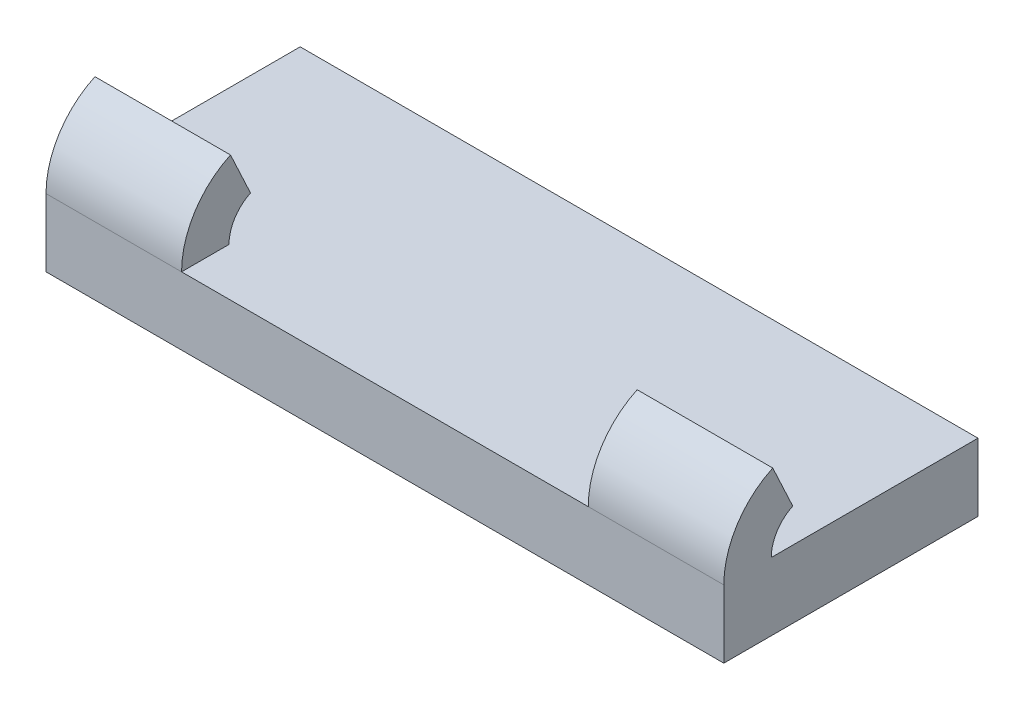
from build123d import *

# Parameters (mm, degrees)
SKETCH1_W           = 50.8
SKETCH1_H           = 19.05
BOSS_EXTRUDE1_DEPTH = 5.08
SKETCH2_W           = 10.16
SKETCH2_H           = 3.556
REVOLVE1_ANGLE      = 65


with BuildPart() as part:
    # Sketch1 → Boss-Extrude1 (new body)
    with BuildSketch(Plane(origin=(0, 0, 0), x_dir=(1, 0, 0), z_dir=(0, 1, 0))):
        with Locations((25.4, -9.525)):
            Rectangle(SKETCH1_W, SKETCH1_H)
    extrude(amount=BOSS_EXTRUDE1_DEPTH)

    # Sketch2 → Revolve1 (revolve)
    with BuildSketch(Plane(origin=(0, 5.08, 0), x_dir=(1, 0, 0), z_dir=(0, 1, 0))):
        with Locations((5.08, -17.272)):
            Rectangle(SKETCH2_W, SKETCH2_H)
        with Locations((45.72, -17.272)):
            Rectangle(SKETCH2_W, SKETCH2_H)
    revolve(axis=Axis((0, 5.08, 12.7), (-1, 0, 0)), revolution_arc=REVOLVE1_ANGLE)


solid = part.part
